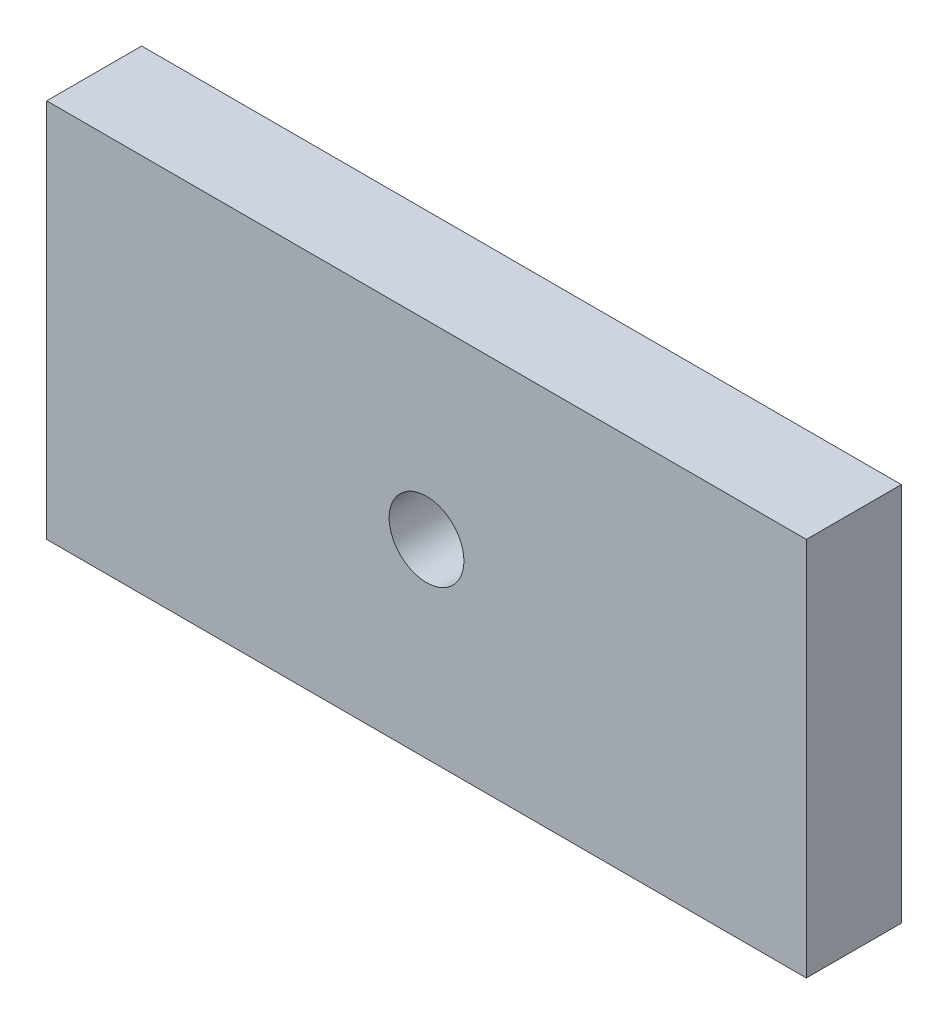
from build123d import *

# Parameters (mm, degrees)
SKETCH1_W           = 76.2
SKETCH1_H           = 38.1
SKETCH1_W_2         = 28
SKETCH1_H_2         = 28
SKETCH1_R           = 3.75
BOSS_EXTRUDE1_DEPTH = 9.525


with BuildPart() as part:
    # Sketch1 → Boss-Extrude1 (new body)
    with BuildSketch(Plane.XY):
        with Locations((38.1, -19.05)):
            Rectangle(SKETCH1_W, SKETCH1_H)
        with Locations((38.1, -19.05)):
            Rectangle(SKETCH1_W_2, SKETCH1_H_2, mode=Mode.SUBTRACT)
        with Locations((38.1, -19.05)):
            Rectangle(SKETCH1_W_2, SKETCH1_H_2)
        with Locations((38.1, -19.05)):
            Circle(SKETCH1_R, mode=Mode.SUBTRACT)
    extrude(amount=BOSS_EXTRUDE1_DEPTH)


solid = part.part
